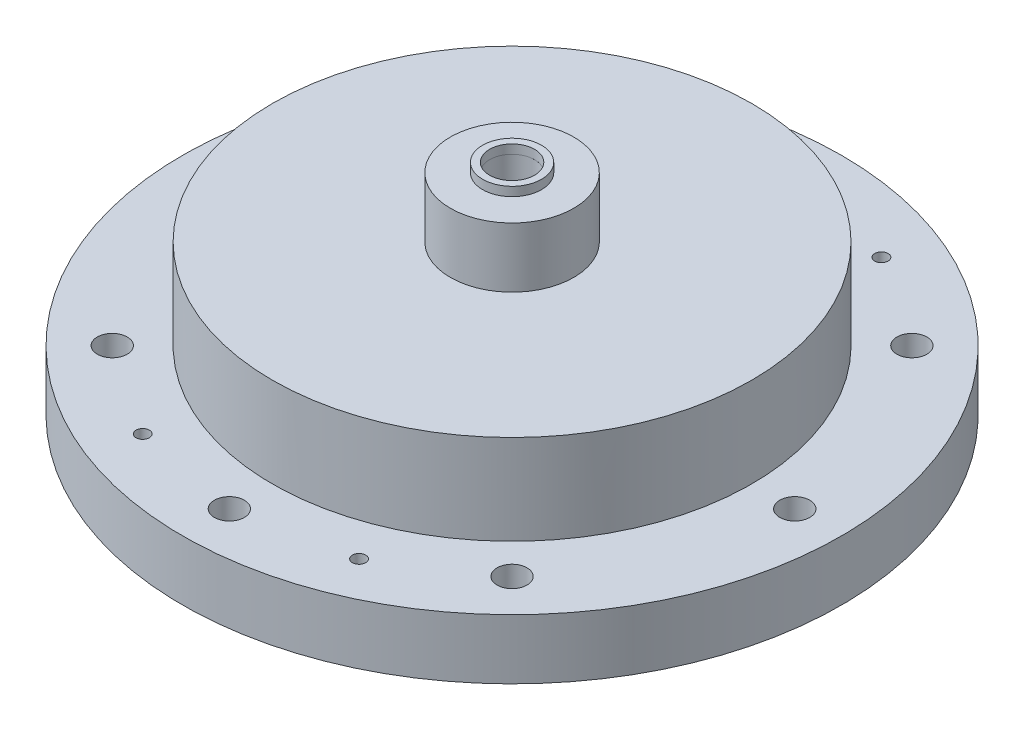
from build123d import *

# Parameters (mm, degrees)
SKETCH1_R           = 50.8
BOSS_EXTRUDE1_DEPTH = 25.4
SKETCH2_R           = 69.85
SKETCH2_R_2         = 50.8
BOSS_EXTRUDE2_DEPTH = 12.7
CUT_EXTRUDE2_REACH  = 27.4
SKETCH4_R           = 3.175
SKETCH5_R           = 12.827
CUT_EXTRUDE3_DEPTH  = 19.05
CUT_EXTRUDE4_REACH  = 8.35
SKETCH6_R           = 1.5875
SKETCH34_R          = 13.081
SKETCH34_R_2        = 4.7625
BOSS_EXTRUDE3_DEPTH = 19.05
SKETCH40_R          = 50.8
BOSS_EXTRUDE5_DEPTH = 6.35
SKETCH38_R          = 6.2484
BOSS_EXTRUDE4_DEPTH = 1.905
SKETCH39_R          = 4.7625
CUT_EXTRUDE7_DEPTH  = 50.8
SKETCH41_R          = 4.7625
CUT_EXTRUDE8_DEPTH  = 6.35
SKETCH46_R          = 3.175
CUT_EXTRUDE10_DEPTH = 6.35
CUT_EXTRUDE11_START = 6.477
SKETCH49_R          = 23.8252
CUT_EXTRUDE11_DEPTH = 3.937
SKETCH50_R          = 1.4097
CUT_EXTRUDE12_DEPTH = 41.005
SKETCH51_R          = 44.45
CUT_EXTRUDE13_DEPTH = 25.4
SKETCH52_R          = 44.45
SKETCH52_R_2        = 4.7625
BOSS_EXTRUDE6_DEPTH = 25.4
SKETCH53_R          = 44.45
CUT_EXTRUDE14_DEPTH = 25.4


with BuildPart() as part:
    # Sketch1 → Boss-Extrude1 (new body)
    with BuildSketch(Plane(origin=(0, 0, 0), x_dir=(1, 0, 0), z_dir=(0, 1, 0))):
        Circle(SKETCH1_R)
    extrude(amount=BOSS_EXTRUDE1_DEPTH)

    # Sketch2 → Boss-Extrude2 (add)
    with BuildSketch(Plane.XZ):
        Circle(SKETCH2_R)
        Circle(SKETCH2_R_2, mode=Mode.SUBTRACT)
    extrude(amount=-BOSS_EXTRUDE2_DEPTH)

    # Sketch4 → Cut-Extrude2 (cut, up to next)
    with BuildSketch(Plane.XZ, mode=Mode.PRIVATE) as cut_extrude2_sk1:
        with Locations((0, -59.9186)):
            Circle(SKETCH4_R)
    cut_extrude2_tool1 = extrude(cut_extrude2_sk1.sketch, amount=-CUT_EXTRUDE2_REACH, mode=Mode.PRIVATE) & part.part
    add(cut_extrude2_tool1.solids().sort_by_distance((0, 0, -59.9186))[0], mode=Mode.SUBTRACT)
    # Sketch4 → Cut-Extrude2 (cut, up to next)
    with BuildSketch(Plane.XZ, mode=Mode.PRIVATE) as cut_extrude2_sk2:
        with Locations((-42.368848379, -42.368848379)):
            Circle(SKETCH4_R)
    cut_extrude2_tool2 = extrude(cut_extrude2_sk2.sketch, amount=-CUT_EXTRUDE2_REACH, mode=Mode.PRIVATE) & part.part
    add(cut_extrude2_tool2.solids().sort_by_distance((-42.368848, 0, -42.368848))[0], mode=Mode.SUBTRACT)
    # Sketch4 → Cut-Extrude2 (cut, up to next)
    with BuildSketch(Plane.XZ, mode=Mode.PRIVATE) as cut_extrude2_sk3:
        with Locations((-59.9186, 0)):
            Circle(SKETCH4_R)
    cut_extrude2_tool3 = extrude(cut_extrude2_sk3.sketch, amount=-CUT_EXTRUDE2_REACH, mode=Mode.PRIVATE) & part.part
    add(cut_extrude2_tool3.solids().sort_by_distance((-59.9186, 0, 0))[0], mode=Mode.SUBTRACT)
    # Sketch4 → Cut-Extrude2 (cut, up to next)
    with BuildSketch(Plane.XZ, mode=Mode.PRIVATE) as cut_extrude2_sk4:
        with Locations((-42.368848379, 42.368848379)):
            Circle(SKETCH4_R)
    cut_extrude2_tool4 = extrude(cut_extrude2_sk4.sketch, amount=-CUT_EXTRUDE2_REACH, mode=Mode.PRIVATE) & part.part
    add(cut_extrude2_tool4.solids().sort_by_distance((-42.368848, 0, 42.368848))[0], mode=Mode.SUBTRACT)
    # Sketch4 → Cut-Extrude2 (cut, up to next)
    with BuildSketch(Plane.XZ, mode=Mode.PRIVATE) as cut_extrude2_sk5:
        with Locations((0, 59.9186)):
            Circle(SKETCH4_R)
    cut_extrude2_tool5 = extrude(cut_extrude2_sk5.sketch, amount=-CUT_EXTRUDE2_REACH, mode=Mode.PRIVATE) & part.part
    add(cut_extrude2_tool5.solids().sort_by_distance((0, 0, 59.9186))[0], mode=Mode.SUBTRACT)
    # Sketch4 → Cut-Extrude2 (cut, up to next)
    with BuildSketch(Plane.XZ, mode=Mode.PRIVATE) as cut_extrude2_sk6:
        with Locations((42.368848379, 42.368848379)):
            Circle(SKETCH4_R)
    cut_extrude2_tool6 = extrude(cut_extrude2_sk6.sketch, amount=-CUT_EXTRUDE2_REACH, mode=Mode.PRIVATE) & part.part
    add(cut_extrude2_tool6.solids().sort_by_distance((42.368848, 0, 42.368848))[0], mode=Mode.SUBTRACT)
    # Sketch4 → Cut-Extrude2 (cut, up to next)
    with BuildSketch(Plane.XZ, mode=Mode.PRIVATE) as cut_extrude2_sk7:
        with Locations((59.9186, 0)):
            Circle(SKETCH4_R)
    cut_extrude2_tool7 = extrude(cut_extrude2_sk7.sketch, amount=-CUT_EXTRUDE2_REACH, mode=Mode.PRIVATE) & part.part
    add(cut_extrude2_tool7.solids().sort_by_distance((59.9186, 0, 0))[0], mode=Mode.SUBTRACT)
    # Sketch4 → Cut-Extrude2 (cut, up to next)
    with BuildSketch(Plane.XZ, mode=Mode.PRIVATE) as cut_extrude2_sk8:
        with Locations((42.368848379, -42.368848379)):
            Circle(SKETCH4_R)
    cut_extrude2_tool8 = extrude(cut_extrude2_sk8.sketch, amount=-CUT_EXTRUDE2_REACH, mode=Mode.PRIVATE) & part.part
    add(cut_extrude2_tool8.solids().sort_by_distance((42.368848, 0, -42.368848))[0], mode=Mode.SUBTRACT)

    # Sketch5 → Cut-Extrude3 (cut)
    with BuildSketch(Plane(origin=(0, 25.4, 0), x_dir=(1, 0, 0), z_dir=(0, 1, 0))):
        Circle(SKETCH5_R)
    extrude(amount=-CUT_EXTRUDE3_DEPTH, mode=Mode.SUBTRACT)

    # Sketch6 → Cut-Extrude4 (cut, up to next)
    with BuildSketch(Plane(origin=(0, 6.35, 0), x_dir=(1, 0, 0), z_dir=(0, 1, 0)), mode=Mode.PRIVATE) as cut_extrude4_sk1:
        Circle(SKETCH6_R)
    cut_extrude4_tool1 = extrude(cut_extrude4_sk1.sketch, amount=-CUT_EXTRUDE4_REACH, mode=Mode.PRIVATE) & part.part
    add(cut_extrude4_tool1.solids().sort_by_distance((0, 6.35, 0))[0], mode=Mode.SUBTRACT)

    # Sketch34 → Boss-Extrude3 (add)
    with BuildSketch(Plane(origin=(0, 25.4, 0), x_dir=(1, 0, 0), z_dir=(0, 1, 0))):
        Circle(SKETCH34_R)
        Circle(SKETCH34_R_2, mode=Mode.SUBTRACT)
    extrude(amount=BOSS_EXTRUDE3_DEPTH)

    # Sketch40 → Boss-Extrude5 (add)
    with BuildSketch(Plane(origin=(0, 25.4, 0), x_dir=(1, 0, 0), z_dir=(0, 1, 0))):
        Circle(SKETCH40_R)
    extrude(amount=BOSS_EXTRUDE5_DEPTH)

    # Sketch41 → Cut-Extrude8 (cut)
    with BuildSketch(Plane(origin=(0, 31.75, 0), x_dir=(1, 0, 0), z_dir=(0, 1, 0))):
        Circle(SKETCH41_R)
    extrude(amount=-CUT_EXTRUDE8_DEPTH, mode=Mode.SUBTRACT)

    # Sketch46 → Cut-Extrude10 (cut)
    with BuildSketch(Plane.XZ):
        with Locations((-22.929855511, 55.357568157)):
            Circle(SKETCH46_R)
        with Locations((22.929855511, 55.357568157)):
            Circle(SKETCH46_R)
        with Locations((-22.929855511, -55.357568157)):
            Circle(SKETCH46_R)
        with Locations((22.929855511, -55.357568157)):
            Circle(SKETCH46_R)
    extrude(amount=-CUT_EXTRUDE10_DEPTH, mode=Mode.SUBTRACT)

    # Sketch49 → Cut-Extrude11 (cut)
    with BuildSketch(Plane.XZ.offset(-6.477).offset(CUT_EXTRUDE11_START)):
        Circle(SKETCH49_R)
    extrude(amount=-CUT_EXTRUDE11_DEPTH, mode=Mode.SUBTRACT)

    # Sketch50 → Cut-Extrude12 (cut, through all)
    with BuildSketch(Plane.XZ.offset(-6.35)):
        with Locations((-22.929855511, 55.357568157)):
            Circle(SKETCH50_R)
        with Locations((22.929855511, 55.357568157)):
            Circle(SKETCH50_R)
        with Locations((-22.929855511, -55.357568157)):
            Circle(SKETCH50_R)
        with Locations((22.929855511, -55.357568157)):
            Circle(SKETCH50_R)
    extrude(amount=-CUT_EXTRUDE12_DEPTH, mode=Mode.SUBTRACT)

    # Sketch51 → Cut-Extrude13 (cut)
    with BuildSketch(Plane.XZ):
        Circle(SKETCH51_R)
    extrude(amount=-CUT_EXTRUDE13_DEPTH, mode=Mode.SUBTRACT)

    # Sketch52 → Boss-Extrude6 (add)
    with BuildSketch(Plane(origin=(0, 0, 0), x_dir=(-1, 0, 0), z_dir=(0, -1, 0))):
        Circle(SKETCH52_R)
        Circle(SKETCH52_R_2, mode=Mode.SUBTRACT)
    extrude(amount=-BOSS_EXTRUDE6_DEPTH)

    # Sketch53 → Cut-Extrude14 (cut)
    with BuildSketch(Plane.XZ):
        Circle(SKETCH53_R)
    extrude(amount=-CUT_EXTRUDE14_DEPTH, mode=Mode.SUBTRACT)


with BuildPart() as body_2:
    # Sketch38 → Boss-Extrude4 (new body)
    with BuildSketch(Plane(origin=(0, 44.45, 0), x_dir=(1, 0, 0), z_dir=(0, 1, 0))):
        Circle(SKETCH38_R)
    extrude(amount=BOSS_EXTRUDE4_DEPTH)

    # Sketch39 → Cut-Extrude7 (cut)
    with BuildSketch(Plane(origin=(0, 46.355, 0), x_dir=(1, 0, 0), z_dir=(0, 1, 0))):
        Circle(SKETCH39_R)
    extrude(amount=-CUT_EXTRUDE7_DEPTH, mode=Mode.SUBTRACT)


solid = Compound([part.part, body_2.part])
